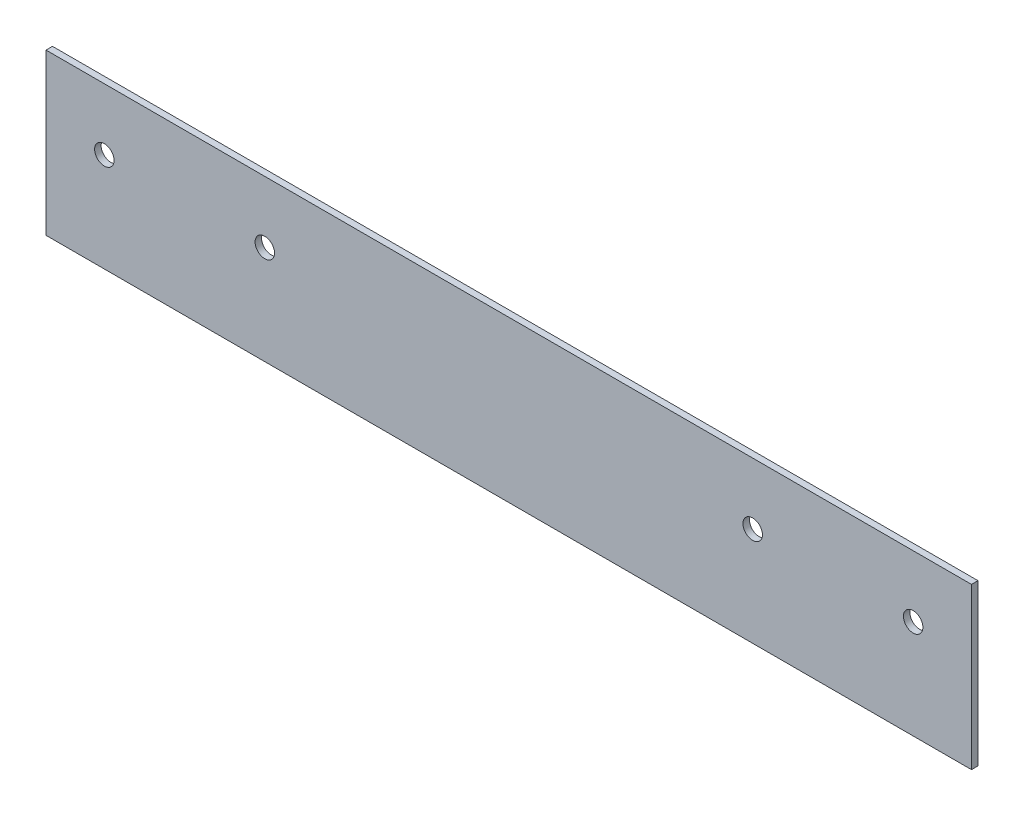
from build123d import *

# Parameters (mm, degrees)
SKETCH1_R           = 3
BOSS_EXTRUDE1_DEPTH = 2


with BuildPart() as part:
    # Sketch1 → Boss-Extrude1 (new body)
    with BuildSketch(Plane.XY):
        Polygon((-142.75, 49.5), (-142.75, 0), (0, 0), (142.75, 0), (142.75, 49.5), align=None)
        with Locations((124.75, 30.5)):
            Circle(SKETCH1_R, mode=Mode.SUBTRACT)
        with Locations((75.25, 30.5)):
            Circle(SKETCH1_R, mode=Mode.SUBTRACT)
        with Locations((-75.25, 30.5)):
            Circle(SKETCH1_R, mode=Mode.SUBTRACT)
        with Locations((-124.75, 30.5)):
            Circle(SKETCH1_R, mode=Mode.SUBTRACT)
    extrude(amount=BOSS_EXTRUDE1_DEPTH)


solid = part.part
